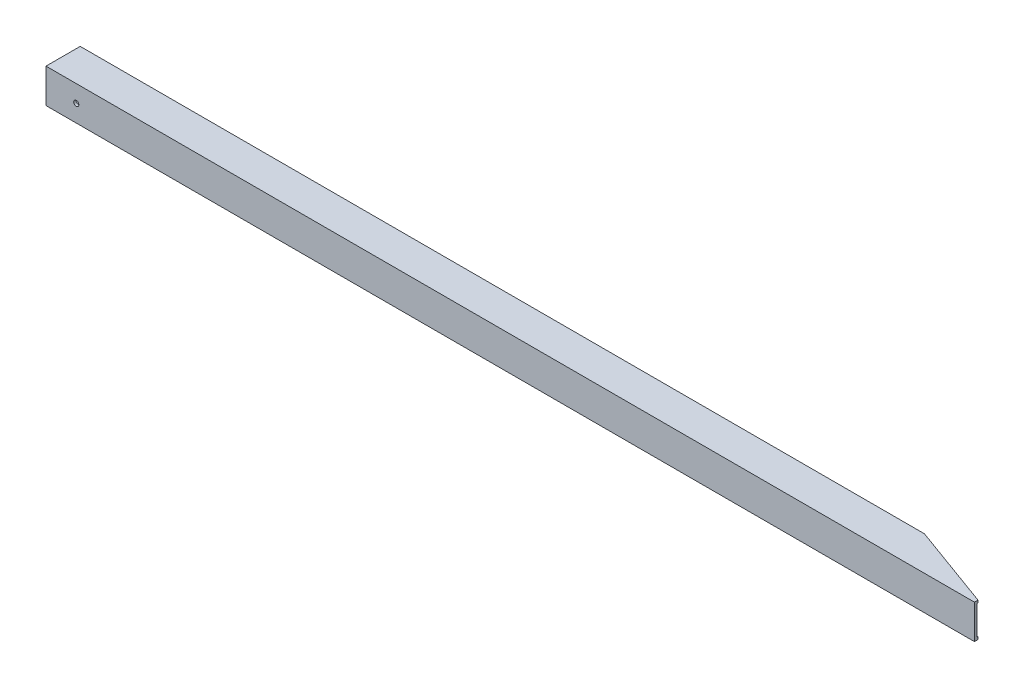
from build123d import *

# Parameters (mm, degrees)
SKETCH1_W               = 44.45
SKETCH1_H               = 44.45
SKETCH1_W_2             = 38.1
SKETCH1_H_2             = 38.1
BOSS_EXTRUDE1_DEPTH     = 1219.2
CUT_EXTRUDE1_DEPTH      = 45.45
F_1_4_CLEARANCE_HOLE1_D = 6.7564
CUT_EXTRUDE2_DEPTH      = 45.45


with BuildPart() as part:
    # Sketch1 → Boss-Extrude1 (new body)
    with BuildSketch(Plane(origin=(0, 0, 0), x_dir=(0, 0, -1), z_dir=(1, 0, 0))):
        with Locations((22.225, 22.225)):
            Rectangle(SKETCH1_W, SKETCH1_H)
        with Locations((22.225, 22.225)):
            Rectangle(SKETCH1_W_2, SKETCH1_H_2, mode=Mode.SUBTRACT)
    extrude(amount=BOSS_EXTRUDE1_DEPTH)

    # Sketch2 → Cut-Extrude1 (cut, through all)
    with BuildSketch(Plane(origin=(0, 44.45, 0), x_dir=(1, 0, 0), z_dir=(0, 1, 0))):
        Polygon((1219.2, 0), (1097.074628705, 44.45), (1219.2, 44.45), align=None)
    extrude(amount=-CUT_EXTRUDE1_DEPTH, mode=Mode.SUBTRACT)

    # 1/4 Clearance Hole1 (through all)
    with Locations(Plane.XY):
        with Locations((39.37, 22.225)):
            Hole(F_1_4_CLEARANCE_HOLE1_D / 2)

    # Sketch5 → Cut-Extrude2 (cut, through all)
    with BuildSketch(Plane(origin=(0, 44.45, 0), x_dir=(1, 0, 0), z_dir=(0, 1, 0))):
        Polygon((1219.2, 0), (1206.5, 0), (1206.5, 4.622421975), align=None)
    extrude(amount=-CUT_EXTRUDE2_DEPTH, mode=Mode.SUBTRACT)


solid = part.part
